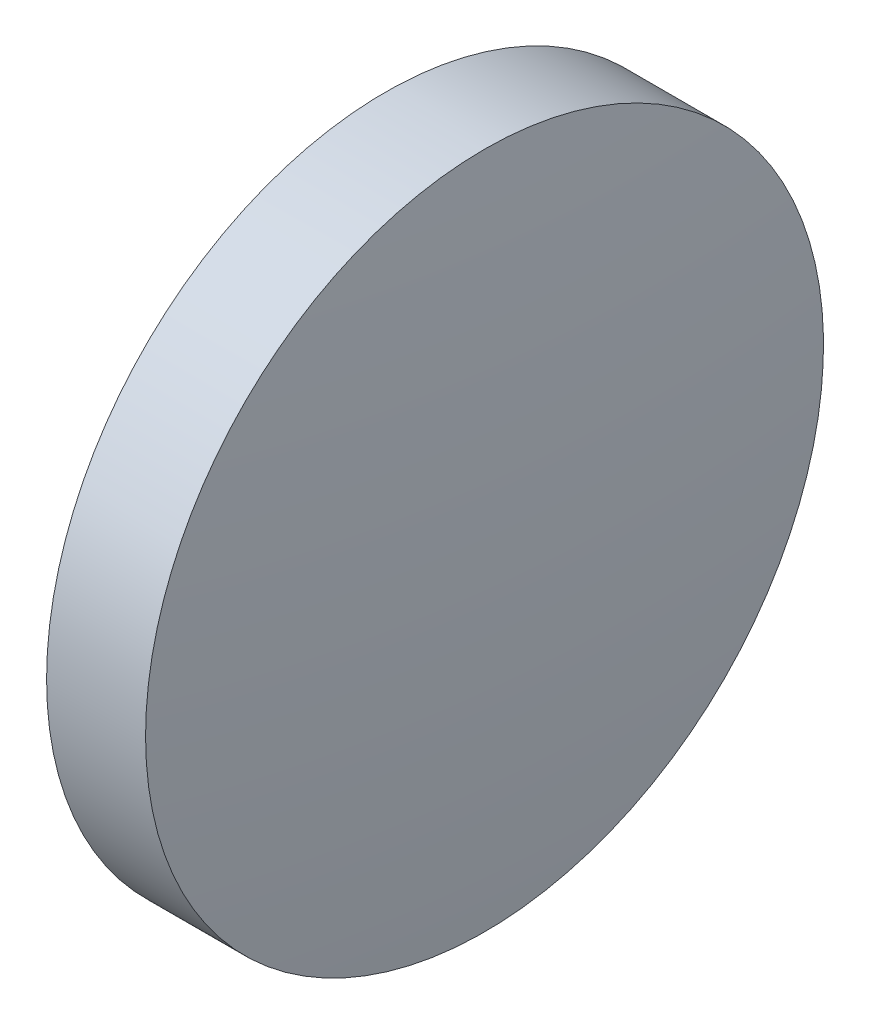
from build123d import *


with BuildPart() as part:
    # 草图1 → 旋转1 (revolve)
    with BuildSketch(Plane.XY):
        with BuildLine():
            Line((422.925540949, 168.369281415), (422.925540949, 173.369281415))
            Line((422.925540949, 173.369281415), (424.385540949, 173.369281415))
            ThreePointArc((424.385540949, 173.369281415), (424.565506429, 170.872159758), (424.625540949, 168.369281415))
            Line((424.625540949, 168.369281415), (422.925540949, 168.369281415))
        make_face()
    revolve(axis=Axis((421.983990478, 168.369281415, 0), (1, 0, 0)))


solid = part.part
